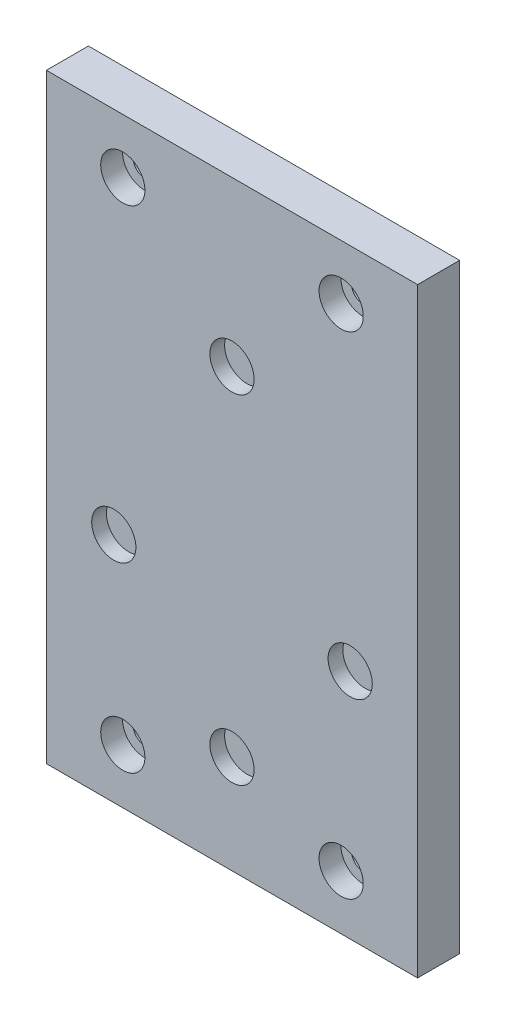
from build123d import *

# Parameters (mm, degrees)
SKETCH1_W           = 68
SKETCH1_H           = 110
SKETCH1_R           = 2.1
SKETCH1_R_2         = 4.05
BOSS_EXTRUDE1_DEPTH = 7.7
SKETCH2_R           = 6.304633146
SKETCH2_R_2         = 7.334333348
SKETCH2_R_3         = 8.114040952
SKETCH2_R_4         = 11.073656437
BOSS_EXTRUDE2_DEPTH = 5
SKETCH3_R           = 4.05
CUT_EXTRUDE1_DEPTH  = 4


with BuildPart() as part:
    # Sketch1 → Boss-Extrude1 (new body)
    with BuildSketch(Plane.XY):
        Rectangle(SKETCH1_W, SKETCH1_H)
        with Locations((20, 45)):
            Circle(SKETCH1_R, mode=Mode.SUBTRACT)
        with Locations((-20, 45)):
            Circle(SKETCH1_R, mode=Mode.SUBTRACT)
        with Locations((20, -45)):
            Circle(SKETCH1_R, mode=Mode.SUBTRACT)
        with Locations((-20, -45)):
            Circle(SKETCH1_R, mode=Mode.SUBTRACT)
        with Locations((21.650635095, -12.5)):
            Circle(SKETCH1_R_2, mode=Mode.SUBTRACT)
        with Locations((0, 25)):
            Circle(SKETCH1_R_2, mode=Mode.SUBTRACT)
        with Locations((-21.650635095, -12.5)):
            Circle(SKETCH1_R_2, mode=Mode.SUBTRACT)
        with Locations((0, -36.95)):
            Circle(SKETCH1_R_2, mode=Mode.SUBTRACT)
    extrude(amount=BOSS_EXTRUDE1_DEPTH)

    # Sketch2 → Boss-Extrude2 (add)
    with BuildSketch(Plane(origin=(0, 0, 0), x_dir=(-1, 0, 0), z_dir=(0, 0, -1))):
        with Locations((-21.650635095, -12.5)):
            Circle(SKETCH2_R)
        with Locations((0, 25)):
            Circle(SKETCH2_R_2)
        with Locations((21.650635095, -12.5)):
            Circle(SKETCH2_R_3)
        with Locations((0, -36.95)):
            Circle(SKETCH2_R_4)
    extrude(amount=-BOSS_EXTRUDE2_DEPTH)

    # Sketch3 → Cut-Extrude1 (cut)
    with BuildSketch(Plane(origin=(0, 0, 7.7), x_dir=(-1, 0, 0), z_dir=(0, 0, -1))):
        with Locations((-20, 45)):
            Circle(SKETCH3_R)
        with Locations((20, 45)):
            Circle(SKETCH3_R)
        with Locations((-20, -45)):
            Circle(SKETCH3_R)
        with Locations((20, -45)):
            Circle(SKETCH3_R)
    extrude(amount=CUT_EXTRUDE1_DEPTH, mode=Mode.SUBTRACT)


solid = part.part
